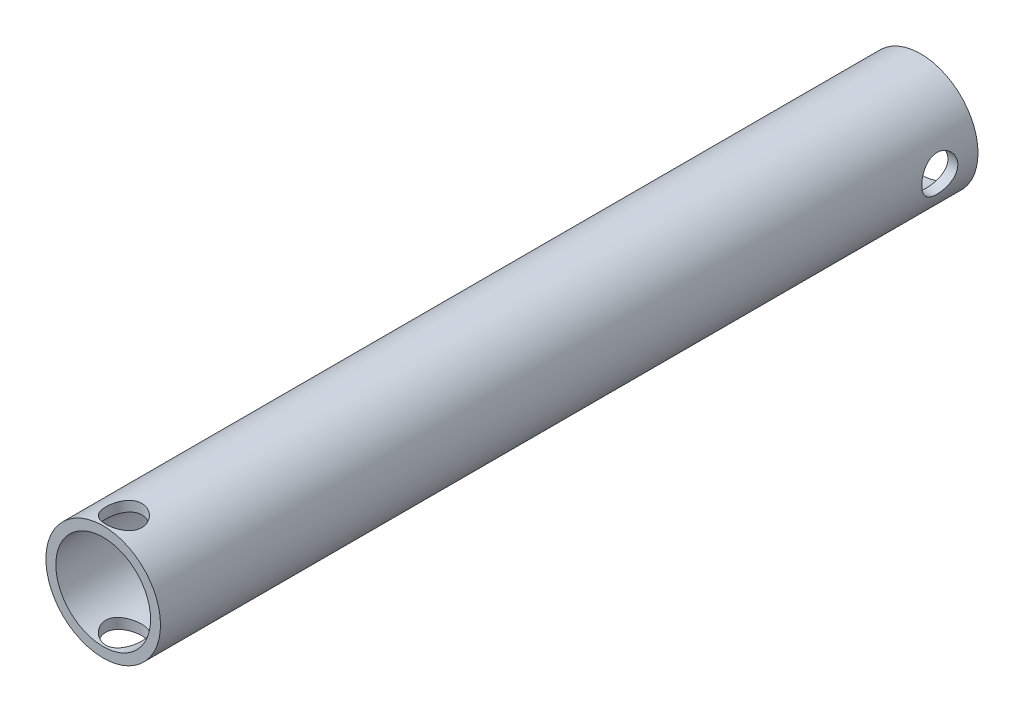
from build123d import *

# Parameters (mm, degrees)
SKETCH1_R           = 9.525
SKETCH1_R_2         = 7.874
BOSS_EXTRUDE1_DEPTH = 135.89
SKETCH2_R           = 3
CUT_EXTRUDE1_DEPTH  = 138.80592
SKETCH3_R           = 3
CUT_EXTRUDE2_DEPTH  = 138.80592


with BuildPart() as part:
    # Sketch1 → Boss-Extrude1 (new body)
    with BuildSketch(Plane.XY):
        Circle(SKETCH1_R)
        Circle(SKETCH1_R_2, mode=Mode.SUBTRACT)
    extrude(amount=BOSS_EXTRUDE1_DEPTH)

    # Sketch2 → Cut-Extrude1 (cut)
    with BuildSketch(Plane(origin=(0, 9.525, 0), x_dir=(1, 0, 0), z_dir=(0, 1, 0))):
        with Locations((0, -132.45592)):
            Circle(SKETCH2_R)
    extrude(amount=-CUT_EXTRUDE1_DEPTH, mode=Mode.SUBTRACT)

    # Sketch3 → Cut-Extrude2 (cut)
    with BuildSketch(Plane(origin=(9.525, 0, 0), x_dir=(0, 0, -1), z_dir=(1, 0, 0))):
        with Locations((-6.35, 0)):
            Circle(SKETCH3_R)
    extrude(amount=-CUT_EXTRUDE2_DEPTH, mode=Mode.SUBTRACT)


solid = part.part
